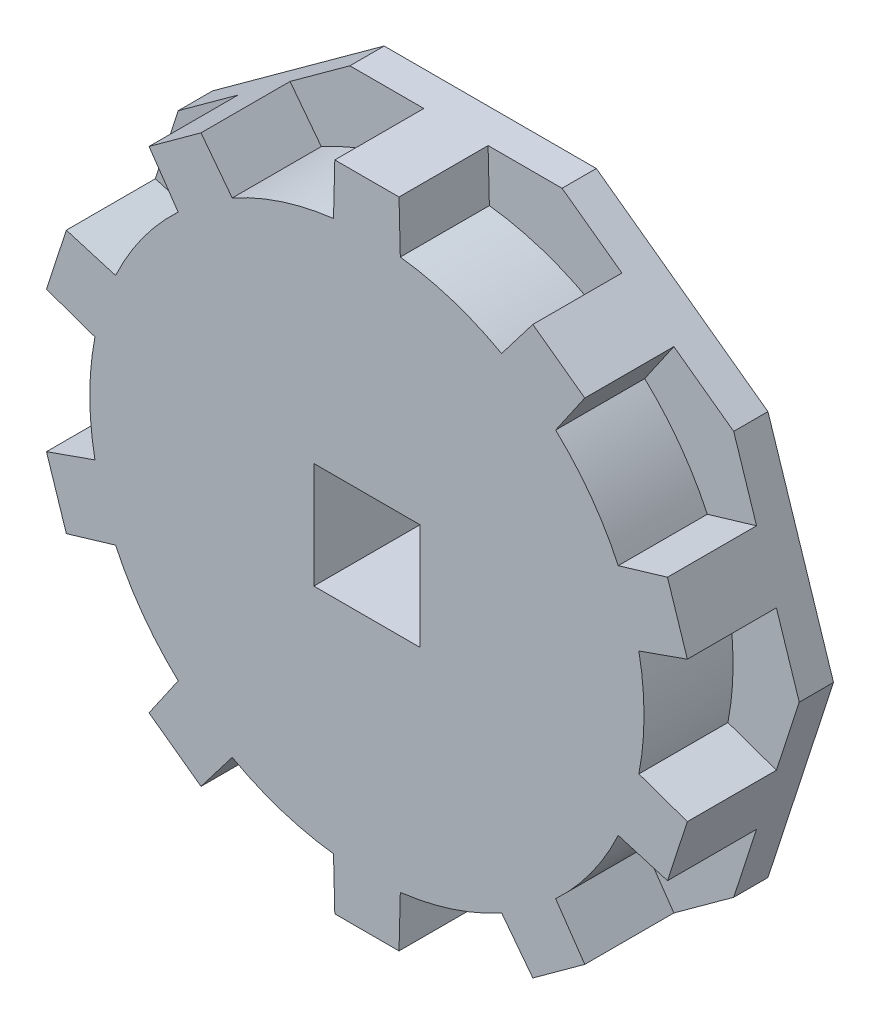
from build123d import *

# Parameters (mm, degrees)
BOSS_EXTRU_1_DEPTH           = 5.2
BOSS_EXTRU_2_DEPTH           = 2
R_P_TITION_CIRCULAIRE1_COUNT = 10
ESQUISSE2_W                  = 6.2
ESQUISSE2_H                  = 6.2
ENL_V_MAT_EXTRU_1_DEPTH      = 8.2


with BuildPart() as part:
    # Esquisse1 → Boss.-Extru.1 (new body)
    with BuildSketch(Plane.XY):
        with BuildLine():
            Line((-5, 15.388417686), (0, 0))
            Line((0, 0), (5, 15.388417686))
            ThreePointArc((5, 15.388417686), (3.491302077, 15.799183798), (1.95, 16.062406385))
            Line((1.95, 16.062406385), (1.875, 19.061468738))
            Line((1.875, 19.061468738), (-1.875, 19.061468738))
            Line((-1.875, 19.061468738), (-1.95, 16.062406385))
            ThreePointArc((-1.95, 16.062406385), (-3.491302077, 15.799183798), (-5, 15.388417686))
        make_face()
    boss_extru_1 = extrude(amount=BOSS_EXTRU_1_DEPTH)

    # Esquisse4 → Boss.-Extru.2 (add)
    with BuildSketch(Plane(origin=(0, 0, 0), x_dir=(-1, 0, 0), z_dir=(0, 0, -1))):
        Polygon((0, 0), (-6.193446632, 19.061468738), (6.193446632, 19.061468738), align=None)
    boss_extru_2 = extrude(amount=BOSS_EXTRU_2_DEPTH)

    # Répétition circulaire1: Boss.-Extru.1, Boss.-Extru.2 ×10 about axis
    r_p_tition_circulaire1_axis = Axis((0, 0, 0), (0, 0, 1))
    for i in range(1, R_P_TITION_CIRCULAIRE1_COUNT):
        add(boss_extru_1.rotate(r_p_tition_circulaire1_axis, i * 360 / R_P_TITION_CIRCULAIRE1_COUNT))
        add(boss_extru_2.rotate(r_p_tition_circulaire1_axis, i * 360 / R_P_TITION_CIRCULAIRE1_COUNT))

    # Esquisse2 → Enlèv. mat.-Extru.1 (cut, through all)
    with BuildSketch(Plane.XY.offset(5.2)):
        Rectangle(ESQUISSE2_W, ESQUISSE2_H)
    extrude(amount=-ENL_V_MAT_EXTRU_1_DEPTH, mode=Mode.SUBTRACT)


solid = part.part
